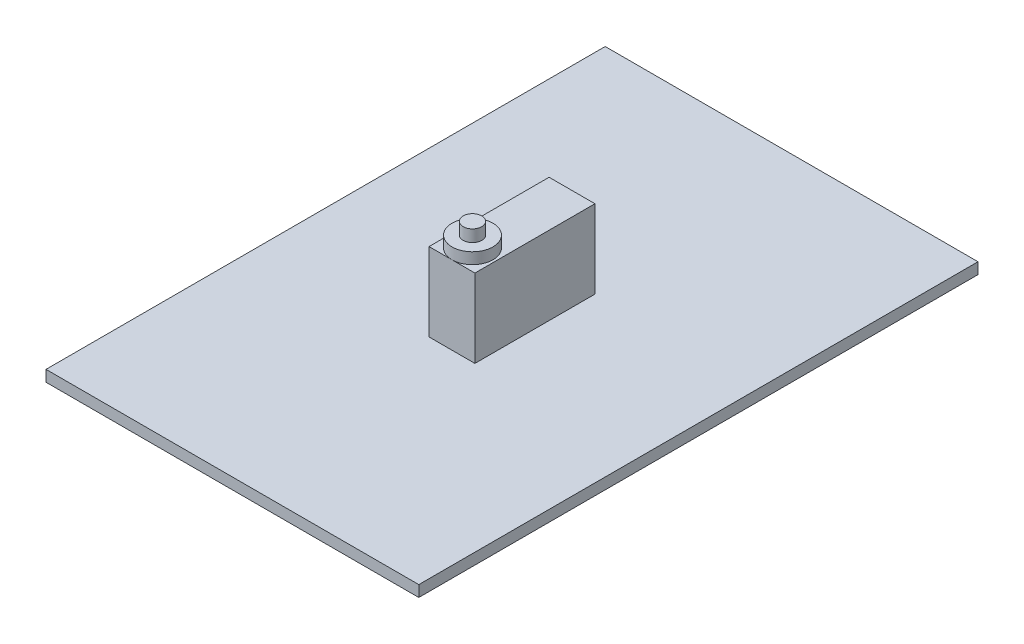
from build123d import *

# Parameters (mm, degrees)
SKETCH2_W           = 100
SKETCH2_H           = 3
BOSS_EXTRUDE2_DEPTH = 150
SKETCH3_W           = 12.3
SKETCH3_H           = 32.2
BOSS_EXTRUDE3_DEPTH = 22.5
SKETCH4_R           = 5.5
BOSS_EXTRUDE4_DEPTH = 3
SKETCH10_R          = 2.5
BOSS_EXTRUDE5_DEPTH = 3.2


with BuildPart() as part:
    # Sketch2 → Boss-Extrude2 (new body)
    with BuildSketch(Plane.XY):
        Rectangle(SKETCH2_W, SKETCH2_H)
    extrude(amount=-BOSS_EXTRUDE2_DEPTH)

    # Sketch3 → Boss-Extrude3 (add)
    with BuildSketch(Plane(origin=(0, 0, 0), x_dir=(1, 0, 0), z_dir=(0, 1, 0))):
        with Locations((0, 75)):
            Rectangle(SKETCH3_W, SKETCH3_H)
    extrude(amount=BOSS_EXTRUDE3_DEPTH)

    # Sketch4 → Boss-Extrude4 (add)
    with BuildSketch(Plane(origin=(0, 22.5, 0), x_dir=(1, 0, 0), z_dir=(0, 1, 0))):
        with Locations((0, 64.4)):
            Circle(SKETCH4_R)
    extrude(amount=BOSS_EXTRUDE4_DEPTH)

    # Sketch10 → Boss-Extrude5 (add)
    with BuildSketch(Plane(origin=(0, 25.5, 0), x_dir=(1, 0, 0), z_dir=(0, 1, 0))):
        with Locations((0, 64.4)):
            Circle(SKETCH10_R)
    extrude(amount=BOSS_EXTRUDE5_DEPTH)


solid = part.part
